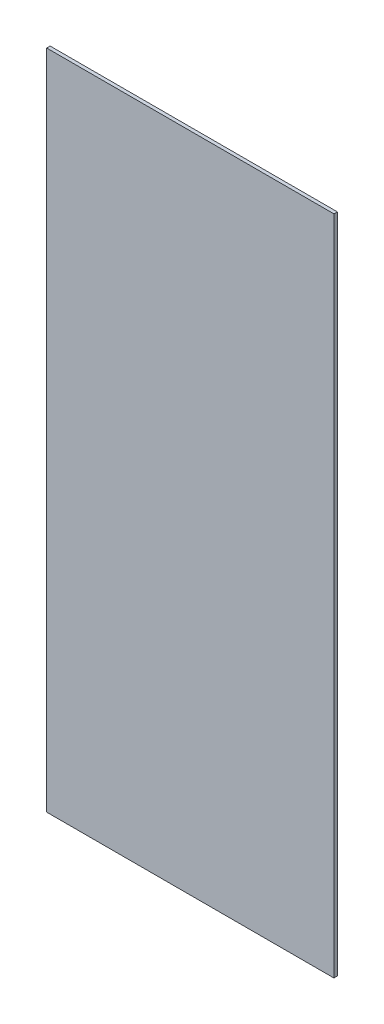
from build123d import *

# Parameters (mm, degrees)
SKETCH1_W           = 250
SKETCH1_H           = 576
BOSS_EXTRUDE1_DEPTH = 3


with BuildPart() as part:
    # Sketch1 → Boss-Extrude1 (new body)
    with BuildSketch(Plane.XY):
        Rectangle(SKETCH1_W, SKETCH1_H)
    extrude(amount=BOSS_EXTRUDE1_DEPTH)


solid = part.part
